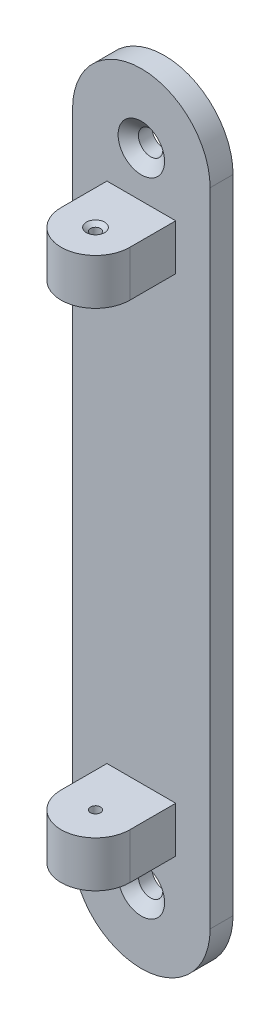
from build123d import *

# Parameters (mm, degrees)
BOSS_EXTRUDE1_DEPTH                                 = 6.35
CSK_FOR_1_4_FLAT_HEAD_MACHINE_SCREW_100_D           = 6.7564
CSK_FOR_1_4_FLAT_HEAD_MACHINE_SCREW_100_CSINK_D     = 12.8778
CSK_FOR_1_4_FLAT_HEAD_MACHINE_SCREW_100_CSINK_ANGLE = 100
SKETCH8_W                                           = 19.05
SKETCH8_H                                           = 12.7
BOSS_EXTRUDE2_DEPTH                                 = 12.7
BOSS_EXTRUDE4_DEPTH                                 = 12.7
CSK_FOR_3_FLAT_HEAD_MACHINE_SCREW_100_D             = 2.794
CSK_FOR_3_FLAT_HEAD_MACHINE_SCREW_100_CSINK_D       = 5.0546
CSK_FOR_3_FLAT_HEAD_MACHINE_SCREW_100_CSINK_ANGLE   = 100


with BuildPart() as part:
    # Sketch2 → Boss-Extrude1 (new body)
    with BuildSketch(Plane.XY):
        with BuildLine():
            Line((0, 0), (0, 88.9))
            ThreePointArc((0, 88.9), (19.05, 107.95), (38.1, 88.9))
            Line((38.1, 88.9), (38.1, 0))
            Line((38.1, 0), (0, 0))
        make_face()
    extrude(amount=BOSS_EXTRUDE1_DEPTH)

    # CSK for 1/4 Flat Head Machine Screw (100)2 (through all)
    with Locations(Plane.XY.offset(6.35)):
        with Locations((19.05, 88.9)):
            CounterSinkHole(CSK_FOR_1_4_FLAT_HEAD_MACHINE_SCREW_100_D / 2, CSK_FOR_1_4_FLAT_HEAD_MACHINE_SCREW_100_CSINK_D / 2, counter_sink_angle=CSK_FOR_1_4_FLAT_HEAD_MACHINE_SCREW_100_CSINK_ANGLE)

    # Sketch8 → Boss-Extrude2 (add)
    with BuildSketch(Plane.XY.offset(6.35)):
        with Locations((19.05, 69.857100744)):
            Rectangle(SKETCH8_W, SKETCH8_H)
    extrude(amount=BOSS_EXTRUDE2_DEPTH)

    # Sketch10 → Boss-Extrude4 (add)
    with BuildSketch(Plane(origin=(0, 76.207100744, 0), x_dir=(1, 0, 0), z_dir=(0, 1, 0))):
        with BuildLine():
            Line((9.525, -19.05), (28.575, -19.05))
            ThreePointArc((28.575, -19.05), (19.05, -28.575), (9.525, -19.05))
        make_face()
    extrude(amount=-BOSS_EXTRUDE4_DEPTH)

    # CSK for #3 Flat Head Machine Screw (100)1 (through all)
    with Locations(Plane(origin=(0, 76.207100744, 0), x_dir=(1, 0, 0), z_dir=(0, 1, 0))):
        with Locations((19.05, -19.05)):
            CounterSinkHole(CSK_FOR_3_FLAT_HEAD_MACHINE_SCREW_100_D / 2, CSK_FOR_3_FLAT_HEAD_MACHINE_SCREW_100_CSINK_D / 2, counter_sink_angle=CSK_FOR_3_FLAT_HEAD_MACHINE_SCREW_100_CSINK_ANGLE)

    # Mirror1: part across plane


with BuildPart() as part_1:
    add(part.part)
    add(part.part.mirror(Plane(origin=(38.1, 0, 6.35), x_dir=(0, 0, 1), z_dir=(0, 1, 0))))


solid = part_1.part
